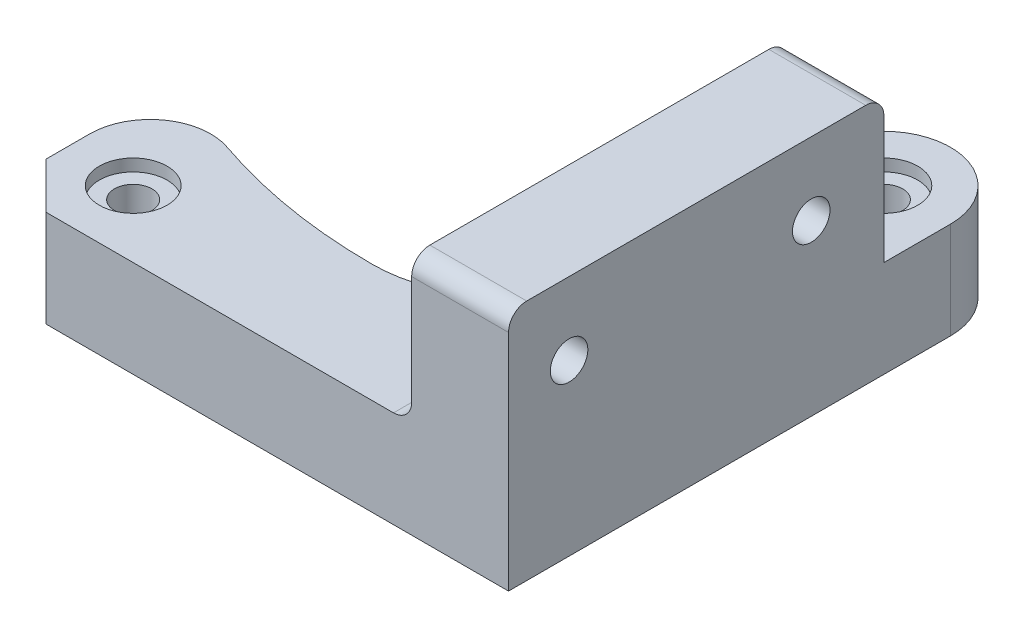
from build123d import *

# Parameters (mm, degrees)
CROQUIS1_R              = 1.55
SALIENTE_EXTRUIR2_DEPTH = 8
REDONDEO1_R             = 8
REDONDEO2_R             = 5
CROQUIS2_R              = 2.8
CORTAR_EXTRUIR1_DEPTH   = 1
CROQUIS3_W              = 8
CROQUIS3_H              = 31
SALIENTE_EXTRUIR3_DEPTH = 12
CROQUIS4_R              = 1.55
CORTAR_EXTRUIR2_DEPTH   = 8
CORTAR_EXTRUIR3_DEPTH   = 2.5
REDONDEO3_R             = 1.5
REDONDEO4_R             = 1.5
CHAFL_N1_SIZE           = 3.8


with BuildPart() as part:
    # Croquis1 → Saliente-Extruir2 (new body)
    with BuildSketch(Plane(origin=(0, 0, 0), x_dir=(1, 0, 0), z_dir=(0, 1, 0))):
        with BuildLine():
            Line((0, 0), (42, 0))
            Line((42, 0), (42, 36.5))
            ThreePointArc((42, 36.5), (37.234408514, 41.950747117), (31.196129406, 37.95566367))
            ThreePointArc((31.196129406, 37.95566367), (26.790448284, 33.865529217), (21, 32.25))
            ThreePointArc((21, 32.25), (32.25, 21), (21, 9.75))
            ThreePointArc((21, 9.75), (10.169247694, 11.081546284), (0, 15.039400798))
            Line((0, 15.039400798), (0, 0))
        make_face()
        with Locations((36.5, 36.5)):
            Circle(CROQUIS1_R, mode=Mode.SUBTRACT)
        with Locations((5.5, 5.5)):
            Circle(CROQUIS1_R, mode=Mode.SUBTRACT)
    extrude(amount=SALIENTE_EXTRUIR2_DEPTH)

    # Redondeo1
    redondeo1_edges = [part.edges().sort_by_distance(p)[0] for p in [
        (21, 4, -32.25),
    ]]
    fillet(redondeo1_edges, radius=REDONDEO1_R)

    # Redondeo2
    redondeo2_edges = [part.edges().sort_by_distance(p)[0] for p in [
        (0, 4, -15.039400798),
    ]]
    fillet(redondeo2_edges, radius=REDONDEO2_R)

    # Croquis2 → Cortar-Extruir1 (cut)
    with BuildSketch(Plane(origin=(0, 8, 0), x_dir=(1, 0, 0), z_dir=(0, 1, 0))):
        with Locations((36.5, 36.5)):
            Circle(CROQUIS2_R)
        with Locations((5.5, 5.5)):
            Circle(CROQUIS2_R)
    extrude(amount=-CORTAR_EXTRUIR1_DEPTH, mode=Mode.SUBTRACT)

    # Croquis3 → Saliente-Extruir3 (add)
    with BuildSketch(Plane(origin=(0, 8, 0), x_dir=(1, 0, 0), z_dir=(0, 1, 0))):
        with Locations((38, 15.5)):
            Rectangle(CROQUIS3_W, CROQUIS3_H)
    extrude(amount=SALIENTE_EXTRUIR3_DEPTH)

    # Croquis4 → Cortar-Extruir2 (cut)
    with BuildSketch(Plane.ZY.offset(-34)):
        with Locations((-25, 14)):
            Circle(CROQUIS4_R)
        with Locations((-5, 14)):
            Circle(CROQUIS4_R)
    extrude(amount=-CORTAR_EXTRUIR2_DEPTH, mode=Mode.SUBTRACT)

    # Croquis5 → Cortar-Extruir3 (cut)
    with BuildSketch(Plane.ZY.offset(-34)):
        Polygon((-25, 17.348631561), (-27.9, 15.674315781), (-27.9, 12.325684219), (-25, 10.651368439), (-22.1, 12.325684219), (-22.1, 15.674315781), align=None)
        Polygon((-5, 17.348631561), (-7.9, 15.674315781), (-7.9, 12.325684219), (-5, 10.651368439), (-2.1, 12.325684219), (-2.1, 15.674315781), align=None)
    extrude(amount=-CORTAR_EXTRUIR3_DEPTH, mode=Mode.SUBTRACT)

    # Redondeo3
    redondeo3_edges = [part.edges().sort_by_distance(p)[0] for p in [
        (34, 8, -15.5),
    ]]
    fillet(redondeo3_edges, radius=REDONDEO3_R)

    # Redondeo4
    redondeo4_edges = [part.edges().sort_by_distance(p)[0] for p in [
        (38, 20, -31),
        (38, 20, 0),
    ]]
    fillet(redondeo4_edges, radius=REDONDEO4_R)

    # Chaflán1
    chafl_n1_edges = [part.edges().sort_by_distance(p)[0] for p in [
        (0, 4, 0),
    ]]
    chamfer(chafl_n1_edges, length=CHAFL_N1_SIZE)


solid = part.part
